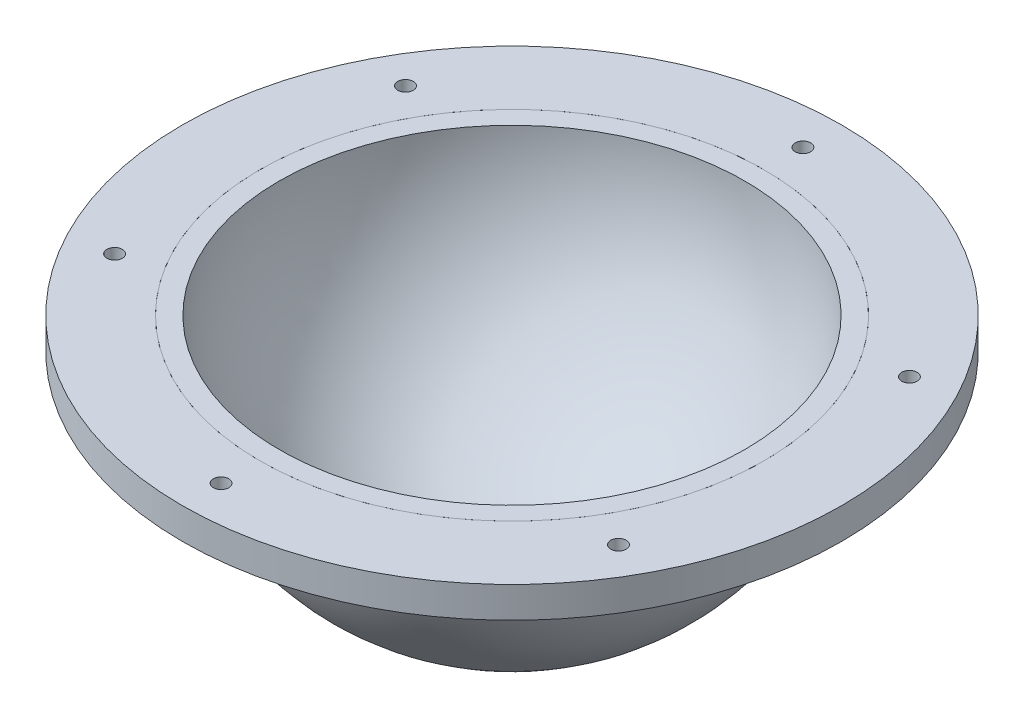
from build123d import *

# Parameters (mm, degrees)
REVOLVE_14_ANGLE    = 180
SKETCH_3_R          = 85
SKETCH_3_R_2        = 65
EXTRUDE_1_DEPTH     = 8
SKETCH_4_R          = 2
CUT_EXTRUDE_2_DEPTH = 66


with BuildPart() as part:
    # 草图1 → 旋转-薄壁14 (revolve)
    with BuildSketch(Plane(origin=(0, 0, 0), x_dir=(1, 0, 0), z_dir=(0, 1, 0))):
        with BuildLine():
            ThreePointArc((0, -65), (65, 0), (0, 65))
            Line((0, 65), (0, 60))
            ThreePointArc((0, 60), (60, 0), (0, -60))
            Line((0, -60), (0, -65))
        make_face()
    revolve(axis=Axis((0, 0, 65), (0, 0, -1)), revolution_arc=REVOLVE_14_ANGLE)


with BuildPart() as body_2:
    # 草图3 → 凸台-拉伸1 (new body)
    with BuildSketch(Plane(origin=(0, 0, 0), x_dir=(1, 0, 0), z_dir=(0, 1, 0))):
        Circle(SKETCH_3_R)
        Circle(SKETCH_3_R_2, mode=Mode.SUBTRACT)
    extrude(amount=-EXTRUDE_1_DEPTH)

    # 草图4 → 切除-拉伸2 (cut, through all)
    with BuildSketch(Plane(origin=(0, 0, 0), x_dir=(1, 0, 0), z_dir=(0, 1, 0))):
        with Locations((0, 75)):
            Circle(SKETCH_4_R)
        with Locations((64.951905284, 37.5)):
            Circle(SKETCH_4_R)
        with Locations((64.951905284, -37.5)):
            Circle(SKETCH_4_R)
        with Locations((0, -75)):
            Circle(SKETCH_4_R)
        with Locations((-64.951905284, -37.5)):
            Circle(SKETCH_4_R)
        with Locations((-64.951905284, 37.5)):
            Circle(SKETCH_4_R)
    extrude(amount=-CUT_EXTRUDE_2_DEPTH, mode=Mode.SUBTRACT)


solid = Compound([part.part, body_2.part])
